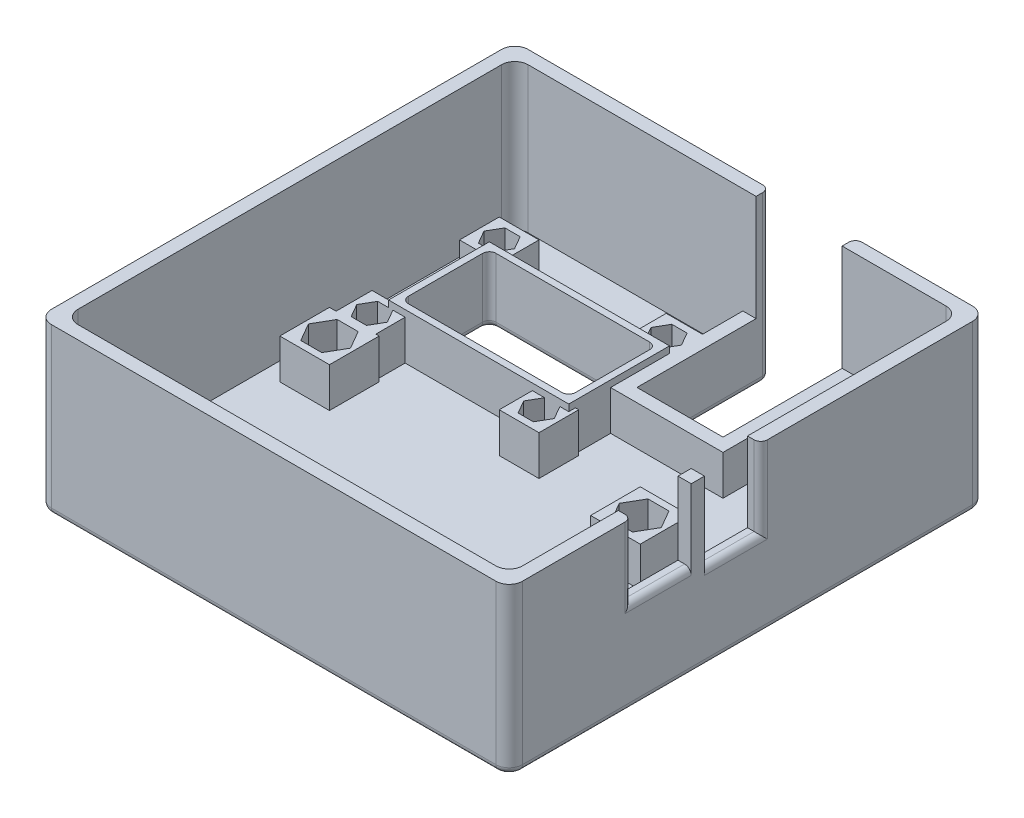
from build123d import *

# Parameters (mm, degrees)
ESBO_O1_W                  = 71.15
ESBO_O1_H                  = 72
RESSALTO_EXTRUS_O1_DEPTH   = 1.5
ESBO_O2_W                  = 71.15
ESBO_O2_H                  = 72
ESBO_O2_W_2                = 67.15
ESBO_O2_H_2                = 68
RESSALTO_EXTRUS_O2_DEPTH   = 22
FILETE1_R                  = 2
ESBO_O3_W                  = 13
ESBO_O3_H                  = 25
CORTE_EXTRUS_O1_DEPTH      = 20
RESSALTO_EXTRUS_O3_DEPTH   = 6
ESBO_O5_W                  = 9
ESBO_O5_H                  = 11
CORTE_EXTRUS_O2_DEPTH      = 1
CORTE_EXTRUS_O2_DEPTH_BACK = 2
ESBO_O6_W                  = 8.5
ESBO_O6_H                  = 12
CORTE_EXTRUS_O3_DEPTH      = 2
ESBO_O7_W                  = 7.5
ESBO_O7_H                  = 7.5
RESSALTO_EXTRUS_O4_DEPTH   = 6
ESBO_O8_W                  = 6
ESBO_O8_H                  = 6
RESSALTO_EXTRUS_O5_DEPTH   = 6
RESSALTO_EXTRUS_O6_DEPTH   = 7
ESBO_O10_W                 = 25.22
ESBO_O10_H                 = 13.22
CORTE_EXTRUS_O4_DEPTH      = 3
FILETE3_R                  = 1
FILETE4_R                  = 1


with BuildPart() as part:
    # Esboço1 → Ressalto-extrusão1 (new body, symmetric)
    with BuildSketch(Plane(origin=(0, 0, 0), x_dir=(1, 0, 0), z_dir=(0, 1, 0))):
        Rectangle(ESBO_O1_W, ESBO_O1_H)
    extrude(amount=RESSALTO_EXTRUS_O1_DEPTH, both=True)

    # Esboço2 → Ressalto-extrusão2 (add)
    with BuildSketch(Plane(origin=(0, 1.5, 0), x_dir=(1, 0, 0), z_dir=(0, 1, 0))):
        Rectangle(ESBO_O2_W, ESBO_O2_H)
        Rectangle(ESBO_O2_W_2, ESBO_O2_H_2, mode=Mode.SUBTRACT)
    extrude(amount=RESSALTO_EXTRUS_O2_DEPTH)

    # Filete1
    filete1_edges = [part.edges().sort_by_distance(p)[0] for p in [
        (-33.575, 12.5, -34),
        (-33.575, 12.5, 34),
        (33.575, 12.5, 34),
        (33.575, 12.5, -34),
        (-35.575, 11, -36),
        (35.575, 11, -36),
        (35.575, 11, 36),
        (-35.575, 11, 36),
    ]]
    fillet(filete1_edges, radius=FILETE1_R)

    # Esboço3 → Corte-extrusão1 (cut)
    with BuildSketch(Plane(origin=(0, 0, -36), x_dir=(-1, 0, 0), z_dir=(0, 0, -1))):
        with Locations((-9.375, 11)):
            Rectangle(ESBO_O3_W, ESBO_O3_H)
    extrude(amount=-CORTE_EXTRUS_O1_DEPTH, mode=Mode.SUBTRACT)

    # Esboço4 → Ressalto-extrusão3 (add)
    with BuildSketch(Plane(origin=(0, 1.5, 0), x_dir=(1, 0, 0), z_dir=(0, 1, 0))):
        Polygon((17.875, 34), (17.875, 14), (0.875, 14), (0.875, 34), (2.875, 34), (2.875, 16), (15.875, 16), (15.875, 34), align=None)
    extrude(amount=RESSALTO_EXTRUS_O3_DEPTH)

    # Esboço5 → Corte-extrusão2 (cut, two sides)
    with BuildSketch(Plane(origin=(35.575, 0, 0), x_dir=(0, 0, -1), z_dir=(1, 0, 0))) as corte_extrus_o2_sk:
        with Locations((-13, 18)):
            Rectangle(ESBO_O5_W, ESBO_O5_H)
    extrude(amount=CORTE_EXTRUS_O2_DEPTH, mode=Mode.SUBTRACT)
    extrude(corte_extrus_o2_sk.sketch, amount=-CORTE_EXTRUS_O2_DEPTH_BACK, mode=Mode.SUBTRACT)

    # Esboço6 → Corte-extrusão3 (cut)
    with BuildSketch(Plane(origin=(35.575, 0, 0), x_dir=(0, 0, -1), z_dir=(1, 0, 0))):
        with Locations((-2.25, 17.5)):
            Rectangle(ESBO_O6_W, ESBO_O6_H)
    extrude(amount=-CORTE_EXTRUS_O3_DEPTH, mode=Mode.SUBTRACT)

    # Esboço7 → Ressalto-extrusão4 (add)
    with BuildSketch(Plane(origin=(0, 1.5, 0), x_dir=(1, 0, 0), z_dir=(0, 1, 0))):
        with Locations((-27.075, -25)):
            Rectangle(ESBO_O7_W, ESBO_O7_H)
        Polygon((-28.66271324, -22.25), (-30.250426481, -25), (-28.66271324, -27.75), (-25.48728676, -27.75), (-23.899573519, -25), (-25.48728676, -22.25), align=None, mode=Mode.SUBTRACT)
        with Locations((19.875, -25)):
            Rectangle(ESBO_O7_W, ESBO_O7_H)
        Polygon((18.28728676, -22.25), (16.699573519, -25), (18.28728676, -27.75), (21.46271324, -27.75), (23.050426481, -25), (21.46271324, -22.25), align=None, mode=Mode.SUBTRACT)
        with Locations((19.875, -0.5)):
            Rectangle(ESBO_O7_W, ESBO_O7_H)
        Polygon((21.46271324, -3.25), (18.28728676, -3.25), (16.699573519, -0.5), (18.28728676, 2.25), (21.46271324, 2.25), (23.050426481, -0.5), align=None, mode=Mode.SUBTRACT)
        with Locations((-27.075, -0.5)):
            Rectangle(ESBO_O7_W, ESBO_O7_H)
        Polygon((-25.48728676, -3.25), (-28.66271324, -3.25), (-30.250426481, -0.5), (-28.66271324, 2.25), (-25.48728676, 2.25), (-23.899573519, -0.5), align=None, mode=Mode.SUBTRACT)
    extrude(amount=RESSALTO_EXTRUS_O4_DEPTH)

    # Esboço8 → Ressalto-extrusão5 (add)
    with BuildSketch(Plane(origin=(0, 1.5, 0), x_dir=(1, 0, 0), z_dir=(0, 1, 0))):
        with Locations((-26.825, 24.9)):
            Rectangle(ESBO_O8_W, ESBO_O8_H)
        Polygon((-27.979700538, 26.9), (-29.134401077, 24.9), (-27.979700538, 22.9), (-25.670299462, 22.9), (-24.515598923, 24.9), (-25.670299462, 26.9), align=None, mode=Mode.SUBTRACT)
        with Locations((-1.605, 24.9)):
            Rectangle(ESBO_O8_W, ESBO_O8_H)
        Polygon((-2.759700538, 26.9), (-3.914401077, 24.9), (-2.759700538, 22.9), (-0.450299462, 22.9), (0.704401077, 24.9), (-0.450299462, 26.9), align=None, mode=Mode.SUBTRACT)
        with Locations((-1.605, 5.68)):
            Rectangle(ESBO_O8_W, ESBO_O8_H)
        Polygon((-2.759700538, 7.68), (-3.914401077, 5.68), (-2.759700538, 3.68), (-0.450299462, 3.68), (0.704401077, 5.68), (-0.450299462, 7.68), align=None, mode=Mode.SUBTRACT)
        with Locations((-26.825, 5.68)):
            Rectangle(ESBO_O8_W, ESBO_O8_H)
        Polygon((-27.979700538, 7.68), (-29.134401077, 5.68), (-27.979700538, 3.68), (-25.670299462, 3.68), (-24.515598923, 5.68), (-25.670299462, 7.68), align=None, mode=Mode.SUBTRACT)
    extrude(amount=RESSALTO_EXTRUS_O5_DEPTH)

    # Esboço9 → Ressalto-extrusão6 (add)
    with BuildSketch(Plane(origin=(0, 1.5, 0), x_dir=(1, 0, 0), z_dir=(0, 1, 0))):
        Polygon((-23.825, 22.9), (-4.605, 22.9), (0.895, 22.9), (0.895, 7.68), (-4.605, 7.68), (-23.825, 7.68), (-26.325, 7.68), (-26.325, 22.9), align=None)
        Polygon((-23.825, 21.9), (-4.605, 21.9), (-0.105, 21.9), (-0.105, 8.68), (-4.605, 8.68), (-23.825, 8.68), (-25.325, 8.68), (-25.325, 21.9), align=None, mode=Mode.SUBTRACT)
    extrude(amount=RESSALTO_EXTRUS_O6_DEPTH)

    # Esboço10 → Corte-extrusão4 (cut)
    with BuildSketch(Plane(origin=(0, 1.5, 0), x_dir=(1, 0, 0), z_dir=(0, 1, 0))):
        with Locations((-12.715, 15.29)):
            Rectangle(ESBO_O10_W, ESBO_O10_H)
    extrude(amount=-CORTE_EXTRUS_O4_DEPTH, mode=Mode.SUBTRACT)

    # Filete3
    filete3_edges = [part.edges().sort_by_distance(p)[0] for p in [
        (-25.325, 3.5, -8.68),
        (-25.325, 3.5, -21.9),
        (-0.105, 3.5, -8.68),
        (-0.105, 3.5, -21.9),
        (-12.715, -1.5, -21.9),
        (-0.105, -1.5, -15.29),
        (-12.715, -1.5, -8.68),
        (-25.325, -1.5, -15.29),
    ]]
    fillet(filete3_edges, radius=FILETE3_R)

    # Filete4
    filete4_edges = [part.edges().sort_by_distance(p)[0] for p in [
        (2.875, -1.5, -26),
        (-15.35, -1.5, -36),
        (-34.989213562, -1.5, -35.414213562),
        (-35.575, -1.5, 0),
        (-34.989213562, -1.5, 35.414213562),
        (0, -1.5, 36),
        (34.989213562, -1.5, 35.414213562),
        (35.575, -1.5, 0),
        (34.989213562, -1.5, -35.414213562),
        (24.725, -1.5, -36),
        (15.875, -1.5, -26),
        (9.375, -1.5, -16),
        (35.575, 18, 17.5),
        (35.575, 12.5, 13),
        (35.575, 11.5, 2.25),
        (35.575, 17.5, -2),
        (15.875, 11, -36),
        (2.875, 11, -36),
    ]]
    fillet(filete4_edges, radius=FILETE4_R)


solid = part.part
